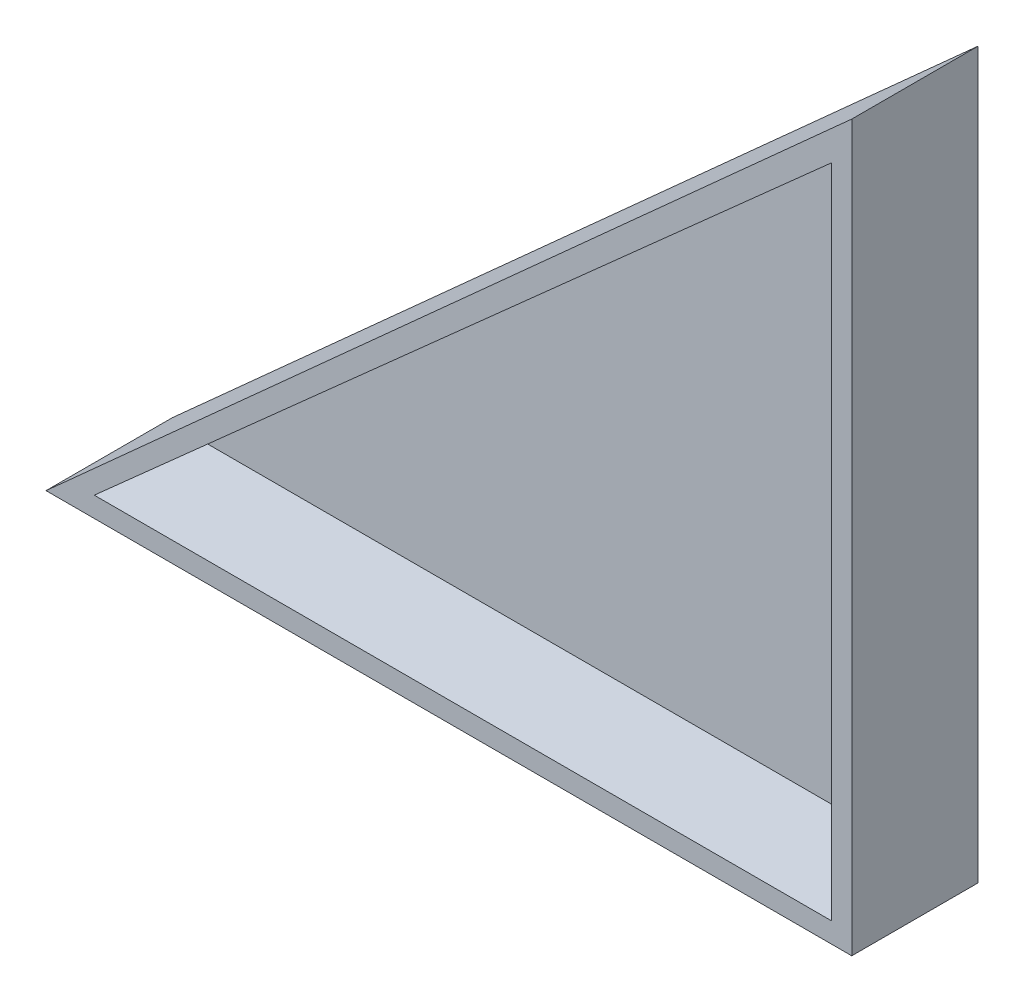
from build123d import *

# Parameters (mm, degrees)
BOSS_EXTRUDE2_DEPTH = 1.5875
BOSS_EXTRUDE3_DEPTH = 7.9375


with BuildPart() as part:
    # Sketch1 → Boss-Extrude2 (new body)
    with BuildSketch(Plane.XY):
        Polygon((33.217447351, 54.34868871), (33.217447351, 13.07368871), (-13.137552649, 13.07368871), align=None)
    extrude(amount=BOSS_EXTRUDE2_DEPTH)

    # Sketch1_5 → Boss-Extrude3 (add)
    with BuildSketch(Plane.XY):
        Polygon((34.487447351, 57.364746686), (34.487447351, 11.80368871), (-16.171808963, 11.80368871), align=None)
        Polygon((33.217447351, 54.34868871), (33.217447351, 13.07368871), (-13.137552649, 13.07368871), align=None, mode=Mode.SUBTRACT)
    extrude(amount=BOSS_EXTRUDE3_DEPTH)


solid = part.part
